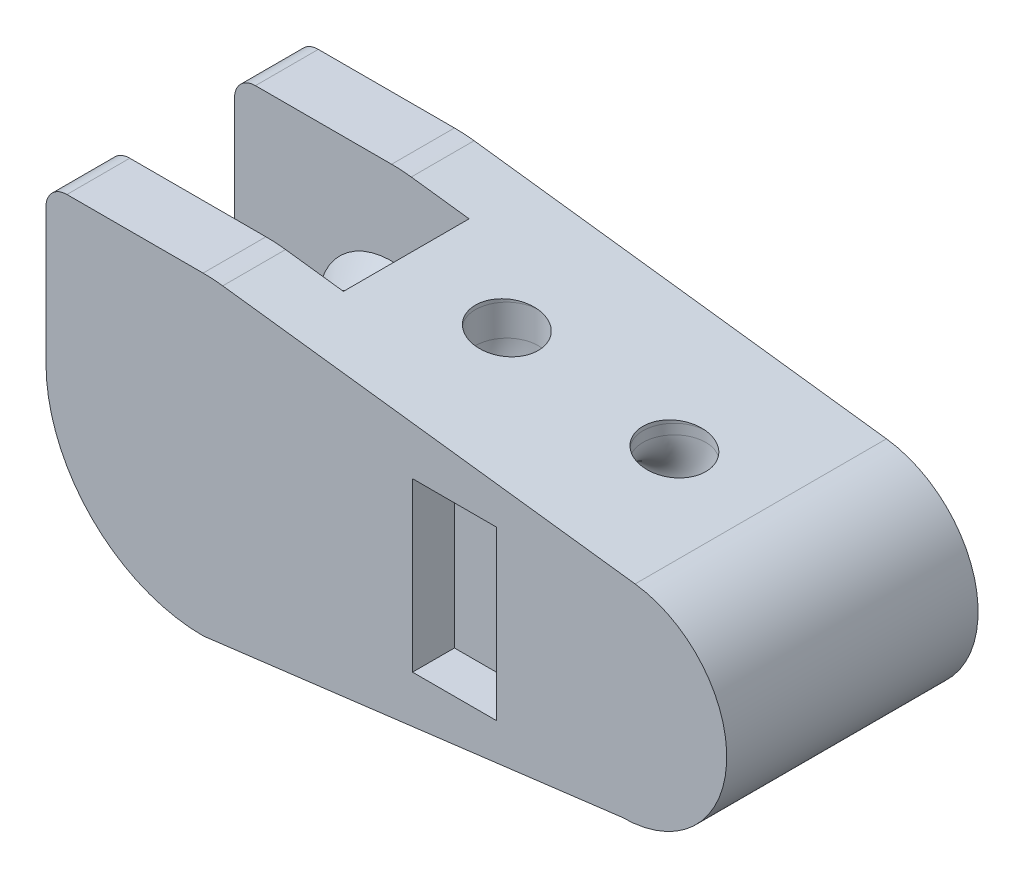
from build123d import *

# Parameters (mm, degrees)
BOSS_EXTRUDE1_DEPTH  = 6
SKETCH1_3_R          = 2.5000000000000004
BOSS_EXTRUDE2_DEPTH  = 6
BOSS_EXTRUDE3_DEPTH  = 6
CUT_EXTRUDE3_DEPTH   = 3
CUT_SWEEP5_PROFILE_R = 1.5
SKETCH1_7_R          = 2.5000000000000004
BOSS_EXTRUDE4_DEPTH  = 6
CHAMFER1_SIZE        = 1
CUT_EXTRUDE4_DEPTH   = 4


with BuildPart() as part:
    # Sketch1 → Boss-Extrude1 (new, symmetric)
    with BuildSketch(Plane.XY):
        with BuildLine():
            Line((10.624999999999998, 4.960783708246109), (-9.062500000000002, 7.4411755623691604))
            ThreePointArc((-9.062499999999998, 7.4411755623691604), (-2.514267183902718, 0.46238966900684386), (-8.153846153846445, -7.269230769230843))
            Line((-8.153846153846452, -7.2692307692308065), (10, -5))
            ThreePointArc((10.000000000000004, -4.999999999999998), (5.009813703816735, 0.31311456271583826), (10.625, 4.9607837082461055))
        make_face()
    extrude(amount=BOSS_EXTRUDE1_DEPTH, both=True)

    # Sketch1_3 → Boss-Extrude2 (add, symmetric)
    with BuildSketch(Plane.XY):
        with BuildLine():
            ThreePointArc((-8.153846153846445, -7.269230769230843), (-2.514267183902718, 0.46238966900684386), (-9.062499999999998, 7.4411755623691604))
            ThreePointArc((-9.062499999999998, 7.4411755623691604), (-9.530328155926242, 7.4852794442749), (-9.999999999999998, 7.5))
            Line((-10, 7.5), (-16.499999999999993, 7.5))
            ThreePointArc((-16.499999999999993, 7.499999999999999), (-17.207106781186546, 7.207106781186547), (-17.5, 6.499999999999993))
            Line((-17.5, 6.499999999999993), (-17.5, 0))
            ThreePointArc((-17.5, 0), (-15.303300858899107, -5.303300858899105), (-10.000000000000002, -7.5))
            Line((-10, -7.5), (-8.153846153846452, -7.2692307692308065))
        make_face()
        with Locations((-10, 0)):
            Circle(SKETCH1_3_R, mode=Mode.SUBTRACT)
    extrude(amount=BOSS_EXTRUDE2_DEPTH, both=True)

    # Sketch1_5 → Boss-Extrude3 (add, symmetric)
    with BuildSketch(Plane.XY):
        with BuildLine():
            ThreePointArc((14.999999999999998, 0), (13.749999999999998, 3.3071891388307373), (10.625, 4.9607837082461055))
            ThreePointArc((10.625, 4.9607837082461055), (5.009813703816735, 0.31311456271583826), (10.000000000000004, -4.999999999999998))
            ThreePointArc((9.999999999999998, -4.999999999999998), (13.535533905932736, -3.5355339059327373), (14.999999999999998, -1.22e-15))
        make_face()
    extrude(amount=BOSS_EXTRUDE3_DEPTH, both=True)

    # Sketch2 → Cut-Extrude3 (cut, symmetric)
    with BuildSketch(Plane.XY):
        with BuildLine():
            Line((-1.9999999999999991, -7.999999999999998), (-2, 9.8e-16))
            ThreePointArc((-2, 9.8e-16), (-4.343145750507631, 5.656854249492391), (-10.000000000000028, 7.999999999999998))
            Line((-10.000000000000028, 7.999999999999998), (-18, 8.108199506438751))
            Line((-18, 8.108199506438751), (-18, -5.586e-14))
            ThreePointArc((-18, -5.586e-14), (-15.656854249492358, -5.656854249492399), (-9.999999999999998, -7.999999999999997))
            Line((-9.999999999999998, -7.9999999999999964), (-1.9999999999999991, -7.999999999999998))
        make_face()
    extrude(amount=CUT_EXTRUDE3_DEPTH, both=True, mode=Mode.SUBTRACT)

    # Cut-Sweep5: sweep along a path in Sketch3
    with BuildLine(Plane.XY) as cut_sweep5_path:
        Line((-1.5, 8.191992315378618), (-1.5, 6.488390119991735))
        Line((-1.5, 6.488390119991735), (-1.5000000000000004, 5.000000000000001))
        ThreePointArc((-1.5000000000000004, 5.000000000000001), (-0.6213203435596422, 2.878679656440358), (1.5000000000000004, 2.0000000000000004))
        Line((1.5000000000000004, 2.0000000000000004), (3.4999999999999987, 1.9999999999999996))
        ThreePointArc((3.4999999999999987, 1.9999999999999996), (5.621320343559642, 2.8786796564403576), (6.5, 5.000000000000001))
        Line((6.5, 5.000000000000001), (6.5, 5.480484858633797))
        Line((6.5, 5.480484858633797), (6.5, 8.191992315378616))
    # Cut-Sweep5 profile (on start of the path) → Cut-Sweep5 (sweep, cut)
    with BuildSketch(Plane(origin=(-1.5, 8.191992315378618, 0), x_dir=(0, 0, -1), z_dir=(0, -1, 0))):
        Circle(CUT_SWEEP5_PROFILE_R)
    cut_sweep5 = sweep(path=cut_sweep5_path.line, mode=Mode.SUBTRACT)

    # Mirror4: Cut-Sweep5 across plane
    add(cut_sweep5.mirror(Plane.ZX), mode=Mode.SUBTRACT)

    # Sketch1_7 → Boss-Extrude4 (add, symmetric)
    with BuildSketch(Plane.XY):
        with Locations((-10, 0)):
            Circle(SKETCH1_7_R)
    extrude(amount=BOSS_EXTRUDE4_DEPTH, both=True)

    # Chamfer1
    chamfer1_edges = [part.edges().sort_by_distance(p)[0] for p in [
        (-12.5, -3.1e-16, 3),
        (-12.5, -3.1e-16, -3),
    ]]
    chamfer(chamfer1_edges, length=CHAMFER1_SIZE)

    # Sketch130 → Cut-Extrude4 (cut, symmetric)
    with BuildSketch(Plane(origin=(0, 0, 0), x_dir=(1, 0, 0), z_dir=(0, 1, 0))):
        Polygon((0, -6), (0, -4), (3, -4), (4.000000000000002, -6), (4.000000000000002, -8.476045259091649), (0, -8.476045259091649), align=None)
    cut_extrude4 = extrude(amount=CUT_EXTRUDE4_DEPTH, both=True, mode=Mode.SUBTRACT)

    # Mirror5: Cut-Extrude4 across plane
    add(cut_extrude4.mirror(Plane.XY), mode=Mode.SUBTRACT)


solid = part.part
